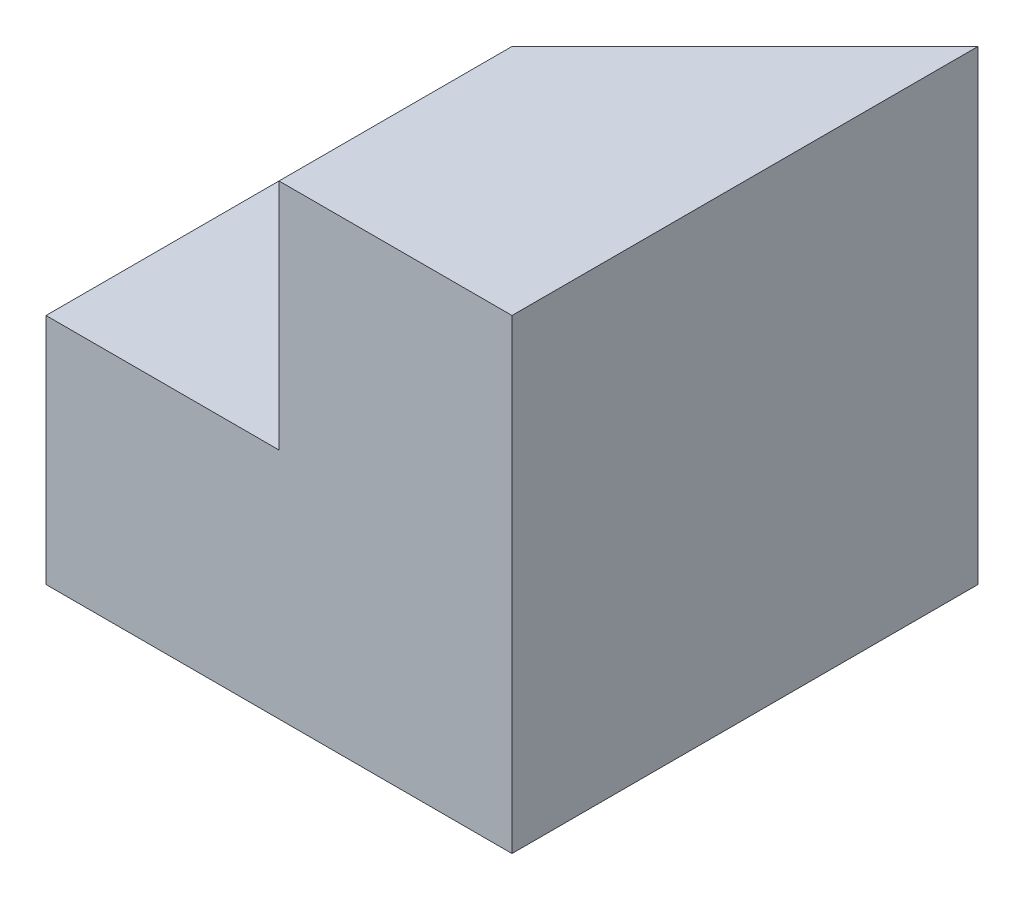
from build123d import *

# Parameters (mm, degrees)
SKETCH1_W           = 40
SKETCH1_H           = 40
BOSS_EXTRUDE1_DEPTH = 40
SKETCH2_W           = 20
SKETCH2_H           = 20
CUT_EXTRUDE1_DEPTH  = 40
CUT_EXTRUDE2_DEPTH  = 20


with BuildPart() as part:
    # Sketch1 → Boss-Extrude1 (new body)
    with BuildSketch(Plane.XY):
        with Locations((20, 20)):
            Rectangle(SKETCH1_W, SKETCH1_H)
    extrude(amount=BOSS_EXTRUDE1_DEPTH)

    # Sketch2 → Cut-Extrude1 (cut)
    with BuildSketch(Plane.XY.offset(40)):
        with Locations((10, 30)):
            Rectangle(SKETCH2_W, SKETCH2_H)
    extrude(amount=-CUT_EXTRUDE1_DEPTH, mode=Mode.SUBTRACT)

    # Sketch3 → Cut-Extrude2 (cut)
    with BuildSketch(Plane(origin=(0, 40, 0), x_dir=(1, 0, 0), z_dir=(0, 1, 0))):
        Polygon((40, 0), (20, -20), (20, 0), align=None)
    extrude(amount=-CUT_EXTRUDE2_DEPTH, mode=Mode.SUBTRACT)


solid = part.part
